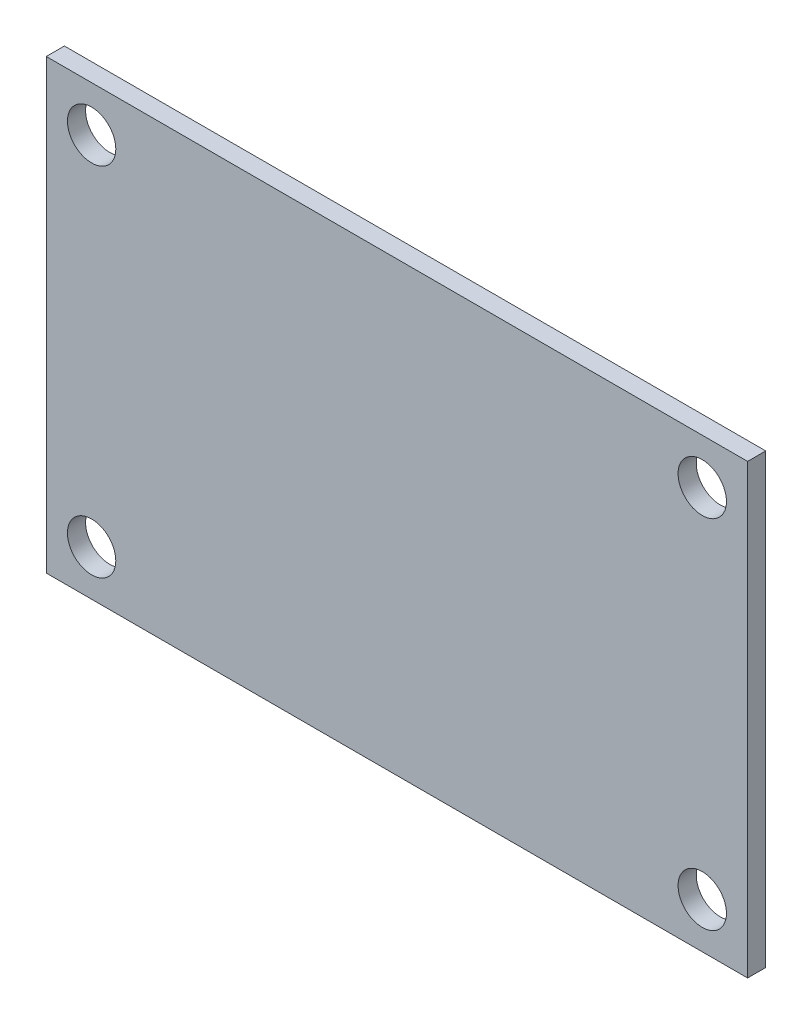
from build123d import *

# Parameters (mm, degrees)
MAIN_SKETCH_W = 58
MAIN_SKETCH_H = 37
MAIN_SKETCH_R = 2
MAIN_DEPTH    = 1.5


with BuildPart() as part:
    # Main-Sketch → Main (new body)
    with BuildSketch(Plane.XY):
        with Locations((29, 18.5)):
            Rectangle(MAIN_SKETCH_W, MAIN_SKETCH_H)
        with Locations((3.75, 33.25)):
            Circle(MAIN_SKETCH_R, mode=Mode.SUBTRACT)
        with Locations((54.25, 33.25)):
            Circle(MAIN_SKETCH_R, mode=Mode.SUBTRACT)
        with Locations((54.25, 3.75)):
            Circle(MAIN_SKETCH_R, mode=Mode.SUBTRACT)
        with Locations((3.75, 3.75)):
            Circle(MAIN_SKETCH_R, mode=Mode.SUBTRACT)
    extrude(amount=MAIN_DEPTH)


solid = part.part
